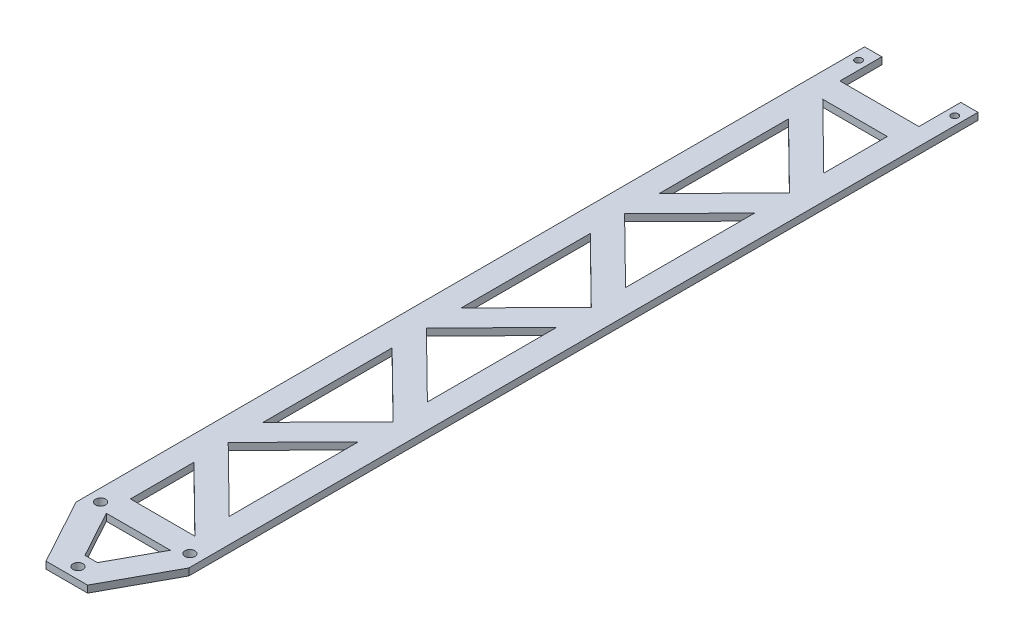
from build123d import *

# Parameters (mm, degrees)
SKETCH1_R           = 1.44
SKETCH1_R_2         = 1
BOSS_EXTRUDE1_DEPTH = 2


with BuildPart() as part:
    # Sketch1 → Boss-Extrude1 (new body)
    with BuildSketch(Plane(origin=(0, 0, 0), x_dir=(1, 0, 0), z_dir=(0, 1, 0))):
        Polygon((-17.332807681, 117.69771489), (-17.332807681, -38.346866508), (-6.997005855, -57.284094596), (4.918028523, -57.284094596), (15.167192319, -38.486712582), (15.167192319, 187.692065716), (10.237192319, 187.692065716), (10.237192319, 175.692065716), (-12.402807681, 175.692065716), (-12.402807681, 187.692065716), (-17.332807681, 187.692065716), align=None)
        with Locations((-13.842807681, -34.799722329)):
            Circle(SKETCH1_R, mode=Mode.SUBTRACT)
        with Locations((-1.042807681, -54.059722329)):
            Circle(SKETCH1_R, mode=Mode.SUBTRACT)
        Polygon((-2.842807681, -50.284094596), (-10.225590468, -36.757379986), (8.137192319, -36.757379986), (0.761829434, -50.284094596), align=None, mode=Mode.SUBTRACT)
        Polygon((8.167192319, -29.757379986), (-10.332807681, -29.757379986), (-10.332807681, -11.546628322), align=None, mode=Mode.SUBTRACT)
        Polygon((8.167192319, -19.934969699), (-10.332807681, -1.724218034), (8.167192319, 17.069624543), align=None, mode=Mode.SUBTRACT)
        with Locations((11.757192319, -34.799722329)):
            Circle(SKETCH1_R, mode=Mode.SUBTRACT)
        Polygon((8.167192319, 27.048047931), (-10.332807681, 8.254205353), (-10.332807681, 45.258799595), align=None, mode=Mode.SUBTRACT)
        Polygon((8.167192319, 36.870458218), (-10.332807681, 55.081209882), (8.167192319, 73.87505246), align=None, mode=Mode.SUBTRACT)
        Polygon((8.167192319, 83.853475847), (-10.332807681, 65.05963327), (-10.332807681, 102.064227512), align=None, mode=Mode.SUBTRACT)
        with Locations((-14.867807681, 183.496000094)):
            Circle(SKETCH1_R_2, mode=Mode.SUBTRACT)
        Polygon((8.167192319, 140.658903764), (-10.361742255, 121.835667033), (-10.361742255, 158.89813761), align=None, mode=Mode.SUBTRACT)
        Polygon((8.167192319, 150.481314052), (-10.332807681, 168.692065716), (8.167192319, 168.692065716), align=None, mode=Mode.SUBTRACT)
        Polygon((8.167192319, 93.675886135), (-10.332807681, 111.886637799), (8.167192319, 130.680480377), align=None, mode=Mode.SUBTRACT)
        with Locations((12.702192319, 183.496000094)):
            Circle(SKETCH1_R_2, mode=Mode.SUBTRACT)
    extrude(amount=BOSS_EXTRUDE1_DEPTH)


solid = part.part
